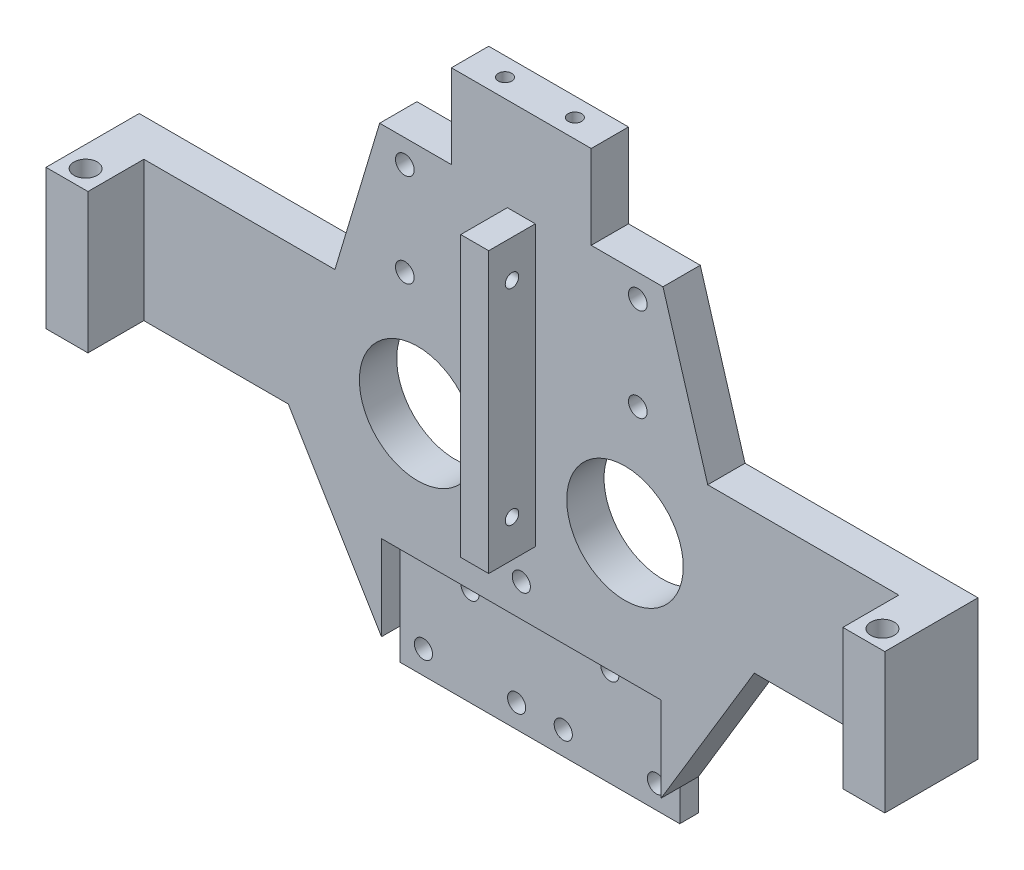
from build123d import *

# Parameters (mm, degrees)
EXTRUDE1_DEPTH                 = 8
EXTRUDE2_DEPTH                 = 8
SKETCH4_W                      = 6
SKETCH4_H                      = 60
EXTRUDE3_DEPTH                 = 10
F_4_0_4_DIAMETER_HOLE2_D       = 4
F_4_0_4_DIAMETER_HOLE2_DEPTH   = 15
SKETCH6_W                      = 9
SKETCH6_H                      = 30
EXTRUDE4_DEPTH                 = 12
F_5_0_5_DIAMETER_HOLE1_D       = 5
F_2_9_2_9_DIAMETER_HOLE1_D     = 2.9
F_2_9_2_9_DIAMETER_HOLE1_DEPTH = 10
SKETCH10_R                     = 12.5
EXTRUDE5_DEPTH                 = 10
F_2_9_2_9_DIAMETER_HOLE2_D     = 2.9
F_2_9_2_9_DIAMETER_HOLE2_DEPTH = 10
EXTRUDE8_DEPTH                 = 21
SKETCH15_W                     = 60
SKETCH15_H                     = 25
EXTRUDE9_DEPTH                 = 4
F_4_0_4_DIAMETER_HOLE4_D       = 3.9
F_4_0_4_DIAMETER_HOLE4_DEPTH   = 15
F_4_0_4_DIAMETER_HOLE5_D       = 3.9
F_4_0_4_DIAMETER_HOLE5_DEPTH   = 15


with BuildPart() as part:
    # Sketch1 → Extrude1 (new body)
    with BuildSketch(Plane.XY):
        Polygon((-40, -10), (-25, 40), (25, 40), (40, -10), (90, -10), (90, -40), (-90, -40), (-90, -10), align=None)
    extrude(amount=EXTRUDE1_DEPTH)

    # Sketch2 → Extrude2 (add)
    with BuildSketch(Plane.XY):
        Polygon((-50, -40), (50, -40), (30, -73.244533262), (30, -80), (-30, -80), (-30, -73.244533262), align=None)
    extrude(amount=EXTRUDE2_DEPTH)

    # Sketch4 → Extrude3 (add)
    with BuildSketch(Plane.XY.offset(8)):
        with Locations((0, -10)):
            Rectangle(SKETCH4_W, SKETCH4_H)
    extrude(amount=EXTRUDE3_DEPTH)

    # Ø4.0 (4) Diameter Hole2
    with Locations(Plane(origin=(25, -3, 0), x_dir=(-1, 0, 0), z_dir=(0, 0, -1))):
        with Locations((0, 0), (50, 0), (0, 20), (50, 20)):
            Hole(F_4_0_4_DIAMETER_HOLE2_D / 2, depth=F_4_0_4_DIAMETER_HOLE2_DEPTH)

    # Sketch6 → Extrude4 (add)
    with BuildSketch(Plane.XY.offset(8)):
        with Locations((-85.5, -25)):
            Rectangle(SKETCH6_W, SKETCH6_H)
    extrude4 = extrude(amount=EXTRUDE4_DEPTH)

    # Ø5.0 (5) Diameter Hole1 (through all)
    with Locations(Plane(origin=(-85.5, -10, 16), x_dir=(0, 0, 1), z_dir=(0, 1, 0))):
        with Locations((0, 0)):
            f_5_0_5_diameter_hole1 = Hole(F_5_0_5_DIAMETER_HOLE1_D / 2)

    # Mirror1: Extrude4, Ø5.0 (5) Diameter Hole1 across plane
    add(extrude4.mirror(Plane(origin=(0, 0, 0), x_dir=(0, 0, 1), z_dir=(1, 0, 0))))
    add(f_5_0_5_diameter_hole1.mirror(Plane(origin=(0, 0, 0), x_dir=(0, 0, 1), z_dir=(1, 0, 0))), mode=Mode.SUBTRACT)

    # Ø2.9 (2.9) Diameter Hole1
    with Locations(Plane(origin=(-7.5, 40, 4), x_dir=(1, 0, 0), z_dir=(0, 1, 0))):
        with Locations((0, 0), (15, 0)):
            Hole(F_2_9_2_9_DIAMETER_HOLE1_D / 2, depth=F_2_9_2_9_DIAMETER_HOLE1_DEPTH)

    # Sketch10 → Extrude5 (cut)
    with BuildSketch(Plane.XY.offset(8)):
        with Locations((-22.248705181, -27.888411791)):
            Circle(SKETCH10_R)
    extrude5 = extrude(amount=-EXTRUDE5_DEPTH, mode=Mode.SUBTRACT)

    # Mirror2: Extrude5 across plane
    add(extrude5.mirror(Plane(origin=(0, 0, 0), x_dir=(0, 0, 1), z_dir=(1, 0, 0))), mode=Mode.SUBTRACT)

    # Ø2.9 (2.9) Diameter Hole2
    with Locations(Plane(origin=(-3, 12, 13), x_dir=(0, -1, 0), z_dir=(-1, 0, 0))):
        with Locations((0, 0), (44, 0)):
            Hole(F_2_9_2_9_DIAMETER_HOLE2_D / 2, depth=F_2_9_2_9_DIAMETER_HOLE2_DEPTH)

    # Sketch14 → Extrude8 (cut, through all)
    with BuildSketch(Plane(origin=(0, 0, 0), x_dir=(-1, 0, 0), z_dir=(0, 0, -1))):
        Polygon((-30.4, 22), (-15, 22), (-15, 40), (-25, 40), align=None)
        Polygon((25, 40), (15, 40), (15, 22), (30.4, 22), align=None)
    extrude(amount=-EXTRUDE8_DEPTH, mode=Mode.SUBTRACT)

    # Sketch15 → Extrude9 (cut)
    with BuildSketch(Plane.XY.offset(8)):
        with Locations((0, -67.5)):
            Rectangle(SKETCH15_W, SKETCH15_H)
    extrude(amount=-EXTRUDE9_DEPTH, mode=Mode.SUBTRACT)

    # Ø4.0 (4) Diameter Hole4
    with Locations(Plane(origin=(15, -59, 4), x_dir=(1, 0, 0), z_dir=(0, 0, 1))):
        with Locations((0, 0), (-10, -16), (10, -16), (-20, -16), (-40, -16), (-30, 0)):
            Hole(F_4_0_4_DIAMETER_HOLE4_D / 2, depth=F_4_0_4_DIAMETER_HOLE4_DEPTH)

    # Ø4.0 (4) Diameter Hole5
    with Locations(Plane(origin=(0, -48, 8), x_dir=(1, 0, 0), z_dir=(0, 0, 1))):
        with Locations((0, 0)):
            Hole(F_4_0_4_DIAMETER_HOLE5_D / 2, depth=F_4_0_4_DIAMETER_HOLE5_DEPTH)


solid = part.part
